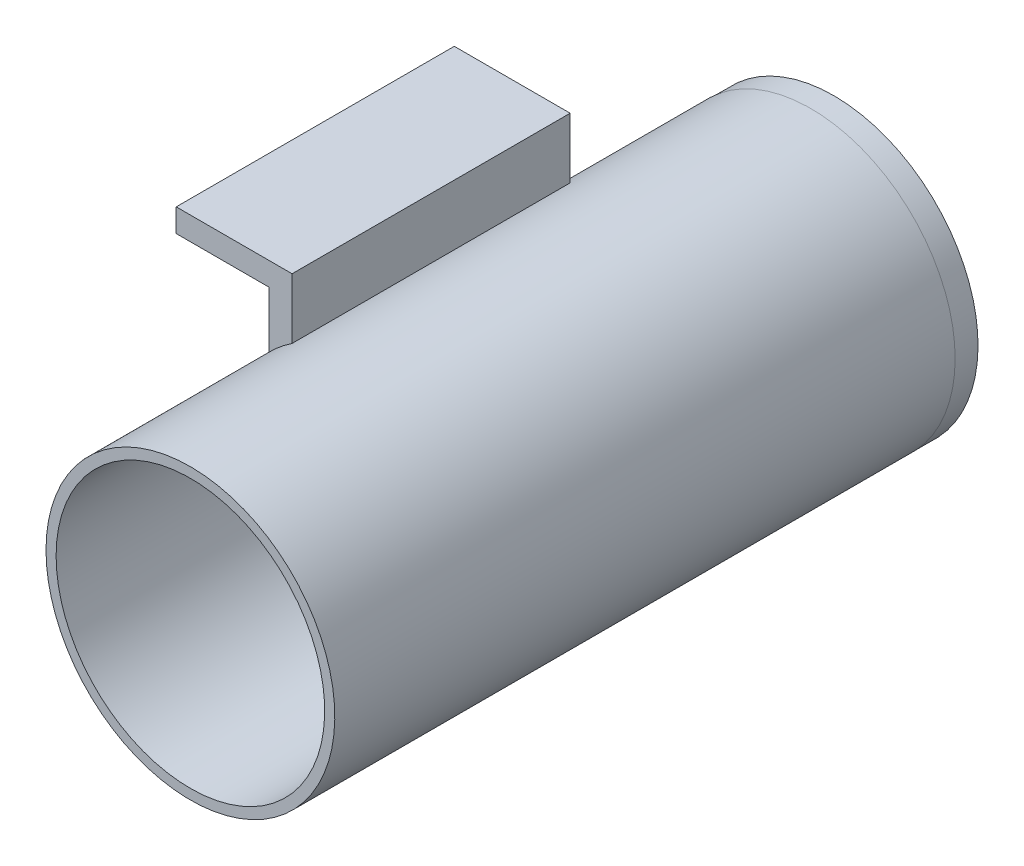
from build123d import *

# Parameters (mm, degrees)
SKETCH1_W                = 12.7
SKETCH1_H                = 3.175
SKETCH1_W_2              = 3.175
SKETCH1_H_2              = 11
BOSS_EXTRUDE1_DEPTH      = 38.1
SKETCH2_R                = 19.784587186
SKETCH2_R_2              = 18.4
BOSS_EXTRUDE2_DEPTH      = 22
BOSS_EXTRUDE2_DEPTH_BACK = 63
SKETCH3_R                = 19.748971086
BOSS_EXTRUDE3_DEPTH      = 3.175
SKETCH4_W                = 2.524062781
SKETCH4_H                = 10.768852164
CUT_EXTRUDE1_DEPTH       = 3.175


with BuildPart() as part:
    # Sketch1 → Boss-Extrude1 (new body)
    with BuildSketch(Plane.XY):
        with Locations((-16.162006615, 10.28820212)):
            Rectangle(SKETCH1_W, SKETCH1_H)
        with Locations((-8.224506615, 6.37570212)):
            Rectangle(SKETCH1_W_2, SKETCH1_H_2)
    extrude(amount=BOSS_EXTRUDE1_DEPTH)

    # Sketch2 → Boss-Extrude2 (add, two sides)
    with BuildSketch(Plane(origin=(0, 0, 0), x_dir=(-1, 0, 0), z_dir=(0, 0, -1))) as boss_extrude2_sk:
        with Locations((-4.329778131, -12.861954284)):
            Circle(SKETCH2_R)
        with Locations((-4.329778131, -12.861954284)):
            Circle(SKETCH2_R_2, mode=Mode.SUBTRACT)
    extrude(amount=BOSS_EXTRUDE2_DEPTH)
    extrude(boss_extrude2_sk.sketch, amount=-BOSS_EXTRUDE2_DEPTH_BACK)

    # Sketch3 → Boss-Extrude3 (add)
    with BuildSketch(Plane(origin=(0, 0, -22), x_dir=(-1, 0, 0), z_dir=(0, 0, -1))):
        with Locations((-4.325565627, -12.897320389)):
            Circle(SKETCH3_R)
    extrude(amount=BOSS_EXTRUDE3_DEPTH)

    # Sketch4 → Cut-Extrude1 (cut)
    with BuildSketch(Plane(origin=(0, 0, -25.175), x_dir=(-1, 0, 0), z_dir=(0, 0, -1))):
        with Locations((-11.516921536, -24.461826694)):
            Rectangle(SKETCH4_W, SKETCH4_H)
    extrude(amount=-CUT_EXTRUDE1_DEPTH, mode=Mode.SUBTRACT)


solid = part.part
